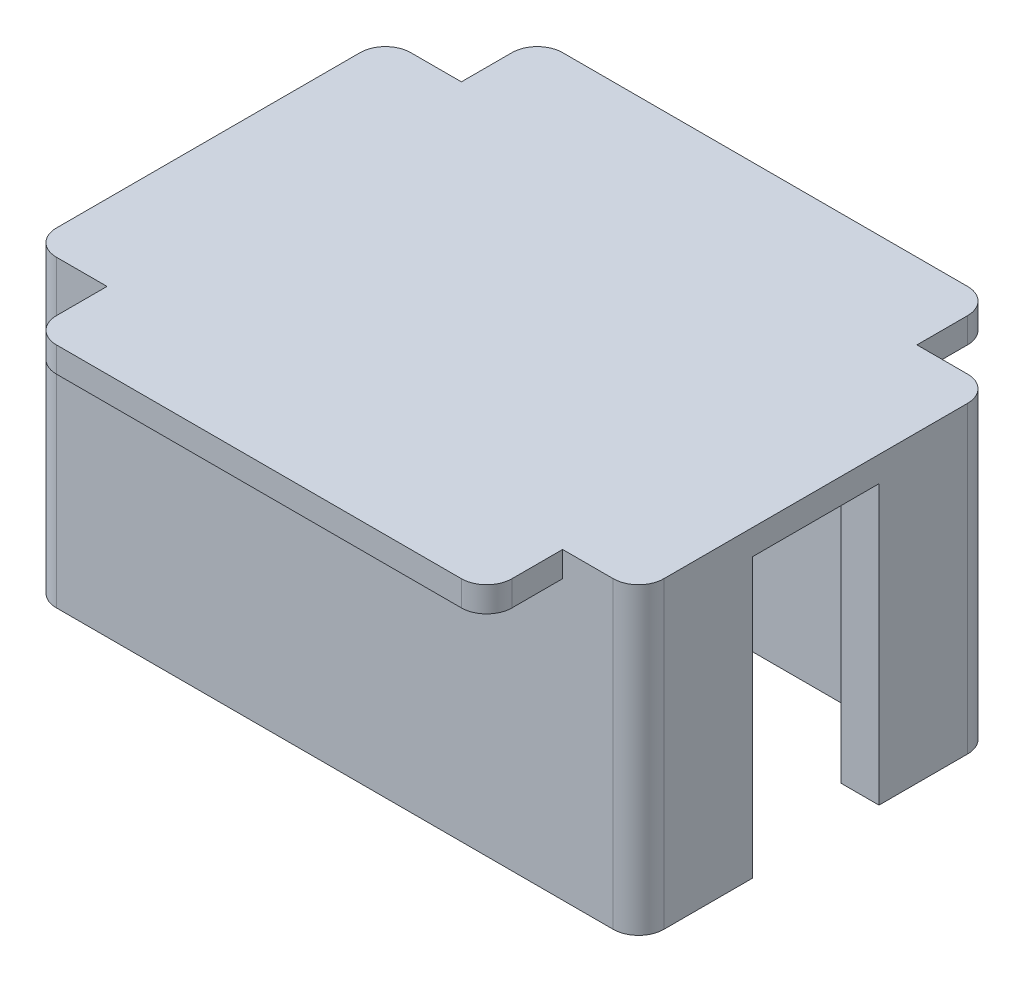
from build123d import *

# Parameters (mm, degrees)
SKETCH6_W            = 48
SKETCH6_H            = 28
SKETCH6_W_2          = 42
SKETCH6_H_2          = 21
BOSS_EXTRUDE20_DEPTH = 22
SKETCH9_W            = 48
SKETCH9_H            = 28
BOSS_EXTRUDE22_DEPTH = 2
FILLET1_R            = 2
SKETCH11_W           = 36
SKETCH11_H           = 6
BOSS_EXTRUDE23_DEPTH = 2
FILLET2_R            = 2
SKETCH12_W           = 3
SKETCH12_H           = 10
CUT_EXTRUDE2_DEPTH   = 22


with BuildPart() as part:
    # Sketch6 → Boss-Extrude20 (new body)
    with BuildSketch(Plane(origin=(0, 0, 0), x_dir=(-1, 0, 0), z_dir=(0, 1, 0))):
        with Locations((-3.5, -2.5)):
            Rectangle(SKETCH6_W, SKETCH6_H)
        with Locations((-3.5, -2.5)):
            Rectangle(SKETCH6_W_2, SKETCH6_H_2, mode=Mode.SUBTRACT)
    extrude(amount=-BOSS_EXTRUDE20_DEPTH)

    # Sketch9 → Boss-Extrude22 (add)
    with BuildSketch(Plane(origin=(0, 0, 0), x_dir=(-1, 0, 0), z_dir=(0, 1, 0))):
        with Locations((-3.5, -2.5)):
            Rectangle(SKETCH9_W, SKETCH9_H)
    extrude(amount=BOSS_EXTRUDE22_DEPTH)

    # Fillet1
    fillet1_edges = [part.edges().sort_by_distance(p)[0] for p in [
        (27.5, -10, 11.5),
        (-20.5, -10, 11.5),
        (-20.5, -10, -16.5),
        (27.5, -10, -16.5),
    ]]
    fillet(fillet1_edges, radius=FILLET1_R)

    # Sketch11 → Boss-Extrude23 (add)
    with BuildSketch(Plane(origin=(0, 2, 0), x_dir=(1, 0, 0), z_dir=(0, 1, 0))):
        with Locations((3.5, 19.5)):
            Rectangle(SKETCH11_W, SKETCH11_H)
        with Locations((3.5, -14.5)):
            Rectangle(SKETCH11_W, SKETCH11_H)
    extrude(amount=-BOSS_EXTRUDE23_DEPTH)

    # Fillet2
    fillet2_edges = [part.edges().sort_by_distance(p)[0] for p in [
        (-14.5, 1, -22.5),
        (21.5, 1, -22.5),
        (21.5, 1, 17.5),
        (-14.5, 1, 17.5),
    ]]
    fillet(fillet2_edges, radius=FILLET2_R)

    # Sketch12 → Cut-Extrude2 (cut)
    with BuildSketch(Plane.XZ.offset(22)):
        with Locations((26, -2.5)):
            Rectangle(SKETCH12_W, SKETCH12_H)
    extrude(amount=-CUT_EXTRUDE2_DEPTH, mode=Mode.SUBTRACT)


solid = part.part
